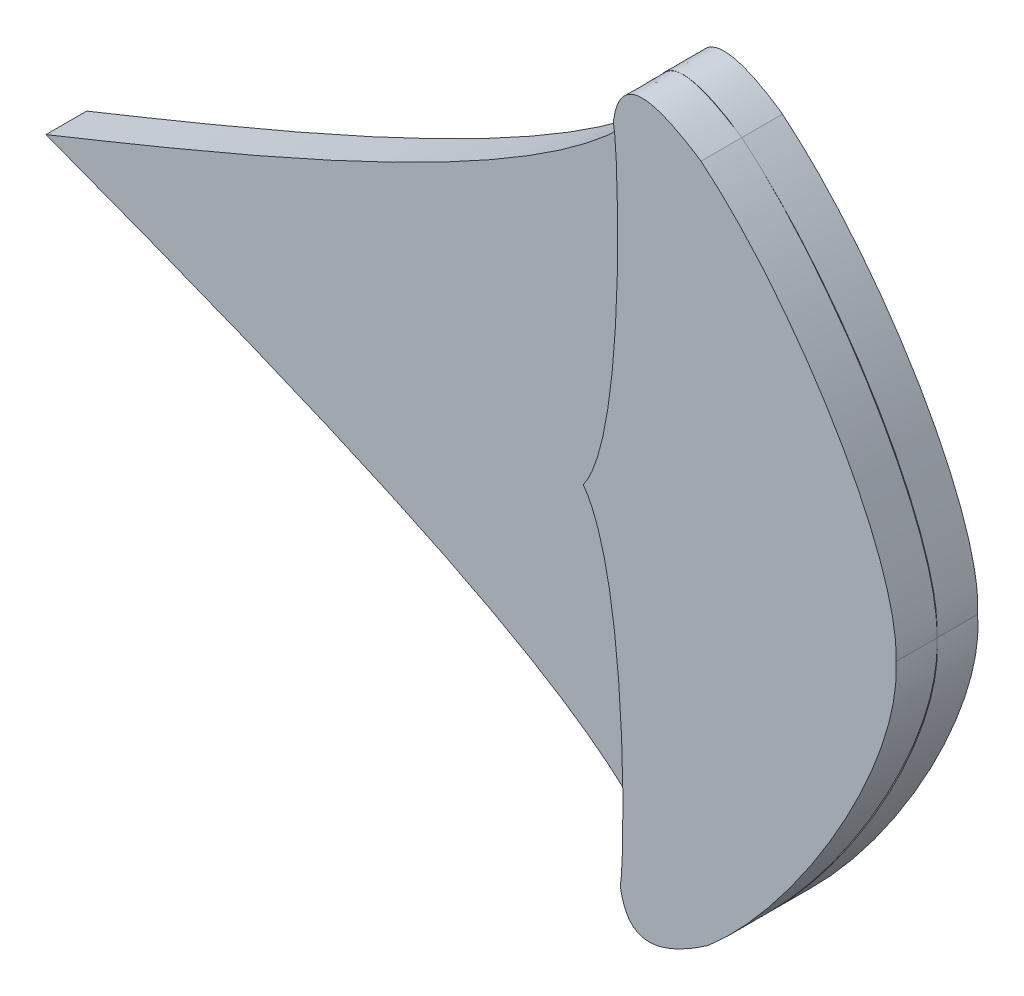
from build123d import *

# Parameters (mm, degrees)
BOSS_EXTRUDE1_DEPTH = 10
BOSS_EXTRUDE2_DEPTH = 10


with BuildPart() as part:
    # Sketch3 → Boss-Extrude1 (new body)
    with BuildSketch(Plane.XY):
        with BuildLine():
            add(Edge.make_bspline(
                [(1191.034746988, 757.646716361), (1192.501595784, 777.278635739), (1169.152381791, 818.53401585), (1143.161995097, 840.068602242)],
                knots=[0, 0, 0, 0, 1, 1, 1, 1], degree=3))
            add(Edge.make_bspline(
                [(1143.161995097, 840.068602242), (1137.274907156, 844.245616795), (1123.106997409, 852.788575192), (1121.635027153, 837.715530595)],
                knots=[0, 0, 0, 0, 1, 1, 1, 1], degree=3))
            add(Edge.make_bspline(
                [(1121.635027153, 837.715530595), (1107.849951403, 810.780397707), (1034.181098513, 780.162460067), (972.400775185, 755.334488692)],
                knots=[0, 0, 0, 0, 1, 1, 1, 1], degree=3))
            add(Edge.make_bspline(
                [(1123.343942812, 676.128061097), (1108.992293291, 702.765625798), (1034.692372372, 731.818676288), (972.400775185, 755.334488692)],
                knots=[0, 0, 0, 0, 1, 1, 1, 1], degree=3))
            add(Edge.make_bspline(
                [(1144.915861455, 674.230794361), (1139.118430881, 669.930206757), (1125.134366982, 661.089518909), (1123.343942812, 676.128061097)],
                knots=[0, 0, 0, 0, 1, 1, 1, 1], degree=3))
            add(Edge.make_bspline(
                [(1191.034746988, 757.646716361), (1192.916467494, 738.050210759), (1170.444995161, 696.310240546), (1144.915861455, 674.230794361)],
                knots=[0, 0, 0, 0, 1, 1, 1, 1], degree=3))
        make_face()
    extrude(amount=BOSS_EXTRUDE1_DEPTH)

    # Sketch4 → Boss-Extrude2 (add)
    with BuildSketch(Plane.XY.offset(10)):
        with BuildLine():
            add(Edge.make_bspline(
                [(1121.635027153, 837.715530595), (1122.994319161, 832.182423063), (1124.969404488, 771.685399193), (1114.266247799, 756.83482859)],
                knots=[0, 0, 0, 0, 1, 1, 1, 1], degree=3))
            add(Edge.make_bspline(
                [(1123.343942812, 676.128061097), (1124.585909874, 681.688679007), (1125.281088513, 742.213943037), (1114.266247799, 756.83482859)],
                knots=[0, 0, 0, 0, 1, 1, 1, 1], degree=3))
            add(Edge.make_bspline(
                [(1123.343942812, 676.128061097), (1125.072838739, 665.157090414), (1132.139531171, 665.40962684), (1144.915861455, 674.230794361)],
                knots=[0, 0, 0, 0, 1, 1, 1, 1], degree=3))
            add(Edge.make_bspline(
                [(1144.915861455, 674.230794361), (1167.477950932, 693.53565223), (1192.361285284, 735.724019033), (1191.034746988, 757.646716361)],
                knots=[0, 0, 0, 0, 1, 1, 1, 1], degree=3))
            add(Edge.make_bspline(
                [(1143.161995097, 840.068602242), (1166.127320819, 821.245232901), (1191.897340609, 779.592565495), (1191.034746988, 757.646716361)],
                knots=[0, 0, 0, 0, 1, 1, 1, 1], degree=3))
            add(Edge.make_bspline(
                [(1121.635027153, 837.715530595), (1123.131508896, 848.720612205), (1130.201961672, 848.617587304), (1143.161995097, 840.068602242)],
                knots=[0, 0, 0, 0, 1, 1, 1, 1], degree=3))
        make_face()
    extrude(amount=BOSS_EXTRUDE2_DEPTH)


solid = part.part
